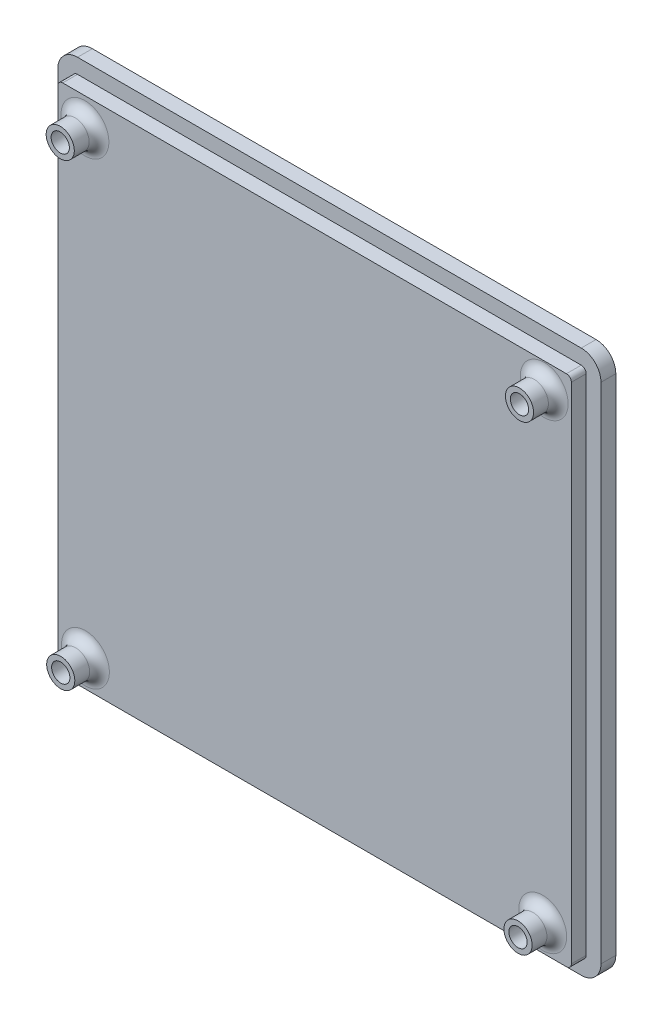
from build123d import *

# Parameters (mm, degrees)
CROQUIS4_W              = 104
CROQUIS4_H              = 104
CROQUIS4_R              = 1.85
SALIENTE_EXTRUIR2_DEPTH = 6
CROQUIS5_R              = 2.85
CROQUIS5_R_2            = 1.85
SALIENTE_EXTRUIR3_DEPTH = 5
REDONDEO1_R             = 2
REDONDEO2_R             = 1
SALIENTE_EXTRUIR4_START = -3
SALIENTE_EXTRUIR4_DEPTH = 3


with BuildPart() as part:
    # Croquis4 → Saliente-Extruir2 (new body)
    with BuildSketch(Plane.XY):
        Rectangle(CROQUIS4_W, CROQUIS4_H)
        with Locations((-46.4, -46.6)):
            Circle(CROQUIS4_R, mode=Mode.SUBTRACT)
        with Locations((46.2, -46.7)):
            Circle(CROQUIS4_R, mode=Mode.SUBTRACT)
        with Locations((-46.5, 46.3)):
            Circle(CROQUIS4_R, mode=Mode.SUBTRACT)
        with Locations((46.5, 46.9)):
            Circle(CROQUIS4_R, mode=Mode.SUBTRACT)
    extrude(amount=SALIENTE_EXTRUIR2_DEPTH)

    # Croquis5 → Saliente-Extruir3 (add)
    # profile 1 of 4: a face of its own
    with BuildSketch(Plane.XY.offset(6)):
        with Locations((-46.5, 46.3)):
            Circle(CROQUIS5_R)
        with Locations((-46.5, 46.3)):
            Circle(CROQUIS5_R_2, mode=Mode.SUBTRACT)
    # profile 2 of 4: a face of its own
    with BuildSketch(Plane.XY.offset(6)):
        with Locations((46.5, 46.9)):
            Circle(CROQUIS5_R)
        with Locations((46.5, 46.9)):
            Circle(CROQUIS5_R_2, mode=Mode.SUBTRACT)
    # profile 3 of 4: a face of its own
    with BuildSketch(Plane.XY.offset(6)):
        with Locations((46.2, -46.7)):
            Circle(CROQUIS5_R)
        with Locations((46.2, -46.7)):
            Circle(CROQUIS5_R_2, mode=Mode.SUBTRACT)
    # profile 4 of 4: a face of its own
    with BuildSketch(Plane.XY.offset(6)):
        with Locations((-46.4, -46.6)):
            Circle(CROQUIS5_R)
        with Locations((-46.4, -46.6)):
            Circle(CROQUIS5_R_2, mode=Mode.SUBTRACT)
    extrude(amount=SALIENTE_EXTRUIR3_DEPTH)

    # Redondeo1
    redondeo1_edges = [part.edges().sort_by_distance(p)[0] for p in [
        (43.35, -46.7, 6),
        (-49.25, -46.6, 6),
        (-49.35, 46.3, 6),
        (43.65, 46.9, 6),
    ]]
    fillet(redondeo1_edges, radius=REDONDEO1_R)

    # Redondeo2
    redondeo2_edges = [part.edges().sort_by_distance(p)[0] for p in [
        (52, -52, 3),
        (-52, -52, 3),
        (-52, 52, 3),
        (52, 52, 3),
    ]]
    fillet(redondeo2_edges, radius=REDONDEO2_R)

    # Croquis6 → Saliente-Extruir4 (add)
    with BuildSketch(Plane(origin=(0, 0, 0), x_dir=(-1, 0, 0), z_dir=(0, 0, -1)).offset(SALIENTE_EXTRUIR4_START)):
        with BuildLine():
            Line((51, 55), (-51, 55))
            ThreePointArc((-51, 55), (-53.828427125, 53.828427125), (-55, 51))
            Line((-55, 51), (-55, -51))
            ThreePointArc((-55, -51), (-53.828427125, -53.828427125), (-51, -55))
            Line((-51, -55), (51, -55))
            ThreePointArc((51, -55), (53.828427125, -53.828427125), (55, -51))
            Line((55, -51), (55, 51))
            ThreePointArc((55, 51), (53.828427125, 53.828427125), (51, 55))
        make_face()
        with BuildLine():
            Line((-52, 51), (-52, -51))
            ThreePointArc((-52, -51), (-51.707106781, -51.707106781), (-51, -52))
            Line((-51, -52), (51, -52))
            ThreePointArc((51, -52), (51.707106781, -51.707106781), (52, -51))
            Line((52, -51), (52, 51))
            ThreePointArc((52, 51), (51.707106781, 51.707106781), (51, 52))
            Line((51, 52), (-51, 52))
            ThreePointArc((-51, 52), (-51.707106781, 51.707106781), (-52, 51))
        make_face(mode=Mode.SUBTRACT)
    extrude(amount=SALIENTE_EXTRUIR4_DEPTH)


solid = part.part
